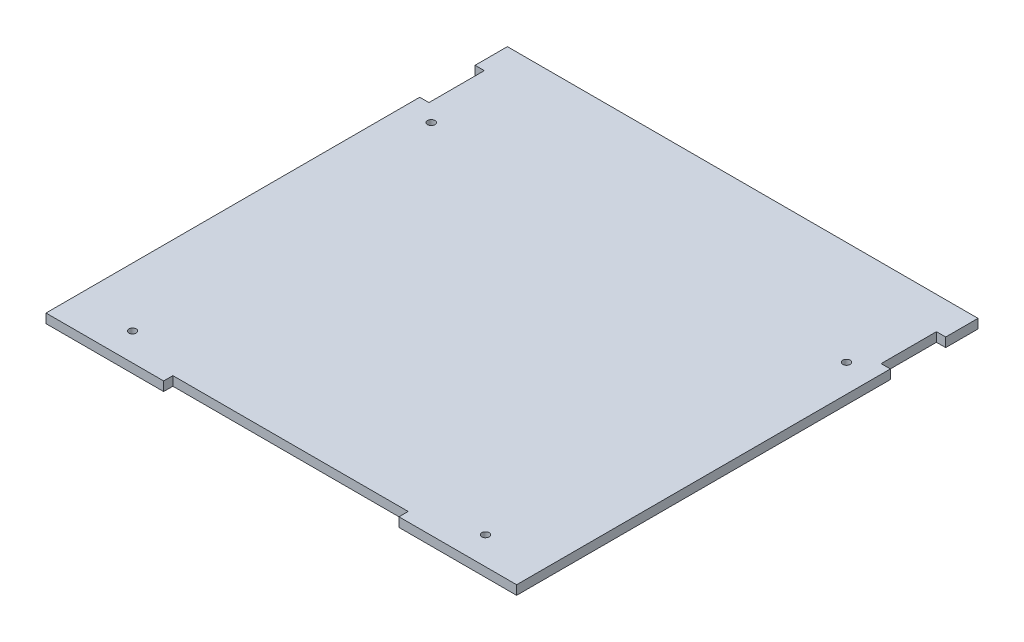
from build123d import *

# Parameters (mm, degrees)
SKETCH2_W           = 255
SKETCH2_H           = 65
BOSS_EXTRUDE1_DEPTH = 5
SKETCH3_W           = 6
SKETCH3_H           = 65
BOSS_EXTRUDE2_DEPTH = 5
SKETCH3_3_W         = 5
SKETCH3_3_H         = 30
CUT_EXTRUDE1_DEPTH  = 10
SKETCH4_W           = 6
SKETCH4_H           = 65
CUT_EXTRUDE2_DEPTH  = 10
SKETCH6_W           = 255
SKETCH6_H           = 5
BOSS_EXTRUDE3_DEPTH = 185
CUT_EXTRUDE3_DEPTH  = 185
SKETCH9_R           = 1.5
CUT_EXTRUDE4_DEPTH  = 185
SKETCH10_R          = 1.5
CUT_EXTRUDE5_DEPTH  = 185
SKETCH11_R          = 2
CUT_EXTRUDE6_DEPTH  = 10


with BuildPart() as part:
    # Sketch2 → Boss-Extrude1 (new body)
    with BuildSketch(Plane(origin=(0, 0, 0), x_dir=(1, 0, 0), z_dir=(0, 1, 0))):
        with Locations((127.5, 32.5)):
            Rectangle(SKETCH2_W, SKETCH2_H)
    extrude(amount=BOSS_EXTRUDE1_DEPTH)

    # Sketch3 → Boss-Extrude2 (add)
    with BuildSketch(Plane(origin=(0, 5, 0), x_dir=(1, 0, 0), z_dir=(0, 1, 0))):
        Polygon((261, 65), (255, 65), (255, 47.5), (255, 17.5), (255, 0), (261, 0), align=None)
        with Locations((-3, 32.5)):
            Rectangle(SKETCH3_W, SKETCH3_H)
    extrude(amount=-BOSS_EXTRUDE2_DEPTH)

    # Sketch3_3 → Cut-Extrude1 (cut)
    with BuildSketch(Plane(origin=(0, 5, 0), x_dir=(1, 0, 0), z_dir=(0, 1, 0))):
        with Locations((252.5, 32.5)):
            Rectangle(SKETCH3_3_W, SKETCH3_3_H)
        with Locations((2.5, 32.5)):
            Rectangle(SKETCH3_3_W, SKETCH3_3_H)
    extrude(amount=-CUT_EXTRUDE1_DEPTH, mode=Mode.SUBTRACT)

    # Sketch4 → Cut-Extrude2 (cut)
    with BuildSketch(Plane.XZ):
        Polygon((255, -47.5), (255, -65), (261, -65), (261, 0), (255, 0), align=None)
        with Locations((-3, -32.5)):
            Rectangle(SKETCH4_W, SKETCH4_H)
    extrude(amount=-CUT_EXTRUDE2_DEPTH, mode=Mode.SUBTRACT)

    # Sketch6 → Boss-Extrude3 (add)
    with BuildSketch(Plane.XY):
        with Locations((127.5, 2.5)):
            Rectangle(SKETCH6_W, SKETCH6_H)
    extrude(amount=BOSS_EXTRUDE3_DEPTH)

    # Sketch8 → Cut-Extrude3 (cut)
    with BuildSketch(Plane(origin=(0, 5, 0), x_dir=(1, 0, 0), z_dir=(0, 1, 0))):
        Polygon((127.5, -185), (191.25, -185), (191.25, -180), (127.5, -180), (63.75, -180), (63.75, -185), align=None)
    extrude(amount=-CUT_EXTRUDE3_DEPTH, mode=Mode.SUBTRACT)

    # Sketch9 → Cut-Extrude4 (cut)
    with BuildSketch(Plane(origin=(0, 5, 0), x_dir=(1, 0, 0), z_dir=(0, 1, 0))):
        with Locations((223.125, -170)):
            Circle(SKETCH9_R)
        with Locations((31.875, -170)):
            Circle(SKETCH9_R)
    extrude(amount=-CUT_EXTRUDE4_DEPTH, mode=Mode.SUBTRACT)

    # Sketch10 → Cut-Extrude5 (cut)
    with BuildSketch(Plane(origin=(0, 5, 0), x_dir=(1, 0, 0), z_dir=(0, 1, 0))):
        with Locations((240, 8.75)):
            Circle(SKETCH10_R)
        with Locations((15, 8.75)):
            Circle(SKETCH10_R)
    extrude(amount=-CUT_EXTRUDE5_DEPTH, mode=Mode.SUBTRACT)

    # Sketch11 → Cut-Extrude6 (cut)
    with BuildSketch(Plane(origin=(0, 5, 0), x_dir=(1, 0, 0), z_dir=(0, 1, 0))):
        with Locations((240, 8.75)):
            Circle(SKETCH11_R)
        with Locations((15, 8.75)):
            Circle(SKETCH11_R)
        with Locations((31.875, -170)):
            Circle(SKETCH11_R)
        with Locations((223.125, -170)):
            Circle(SKETCH11_R)
    extrude(amount=-CUT_EXTRUDE6_DEPTH, mode=Mode.SUBTRACT)


solid = part.part
